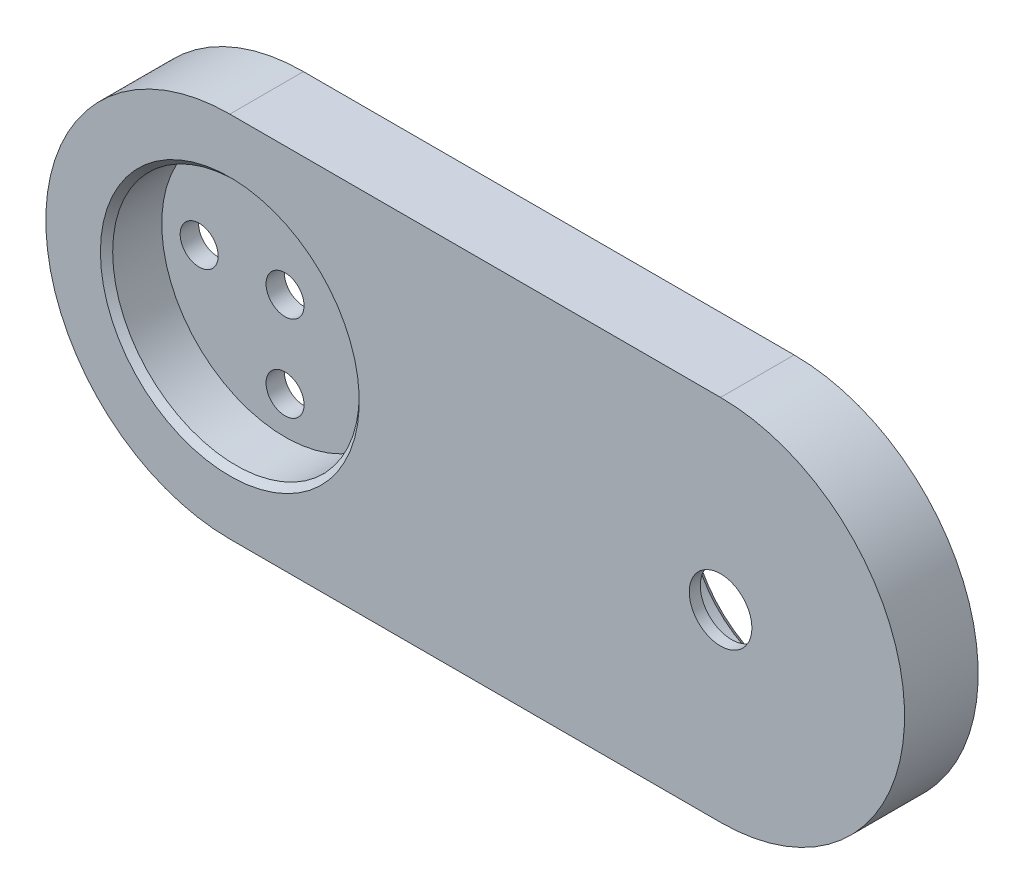
from build123d import *

# Parameters (mm, degrees)
BOSS_EXTRUDE1_DEPTH = 6
SKETCH8_R           = 10.05
CUT_EXTRUDE4_DEPTH  = 4.5
SKETCH9_R           = 7.975
CUT_EXTRUDE5_DEPTH  = 5.1
SKETCH10_R          = 2.55
CUT_EXTRUDE6_DEPTH  = 1.9
SKETCH11_R          = 1.55
CUT_EXTRUDE7_DEPTH  = 2.5
CHAMFER1_SIZE       = 0.5


with BuildPart() as part:
    # Sketch4 → Boss-Extrude1 (new body)
    with BuildSketch(Plane.XY):
        with BuildLine():
            Line((-20, 15), (20, 15))
            ThreePointArc((20, 15), (35, 0), (20, -15))
            Line((20, -15), (-20, -15))
            ThreePointArc((-20, -15), (-35, 0), (-20, 15))
        make_face()
    extrude(amount=BOSS_EXTRUDE1_DEPTH)

    # Sketch8 → Cut-Extrude4 (cut)
    with BuildSketch(Plane.XY.offset(6)):
        with Locations((-20, 0)):
            Circle(SKETCH8_R)
    extrude(amount=-CUT_EXTRUDE4_DEPTH, mode=Mode.SUBTRACT)

    # Sketch9 → Cut-Extrude5 (cut)
    with BuildSketch(Plane(origin=(0, 0, 0), x_dir=(-1, 0, 0), z_dir=(0, 0, -1))):
        with Locations((-20, 0)):
            Circle(SKETCH9_R)
    extrude(amount=-CUT_EXTRUDE5_DEPTH, mode=Mode.SUBTRACT)

    # Sketch10 → Cut-Extrude6 (cut, through all)
    with BuildSketch(Plane(origin=(0, 0, 5.1), x_dir=(-1, 0, 0), z_dir=(0, 0, -1))):
        with Locations((-20, 0)):
            Circle(SKETCH10_R)
    extrude(amount=-CUT_EXTRUDE6_DEPTH, mode=Mode.SUBTRACT)

    # Sketch11 → Cut-Extrude7 (cut, through all)
    with BuildSketch(Plane.XY.offset(1.5)):
        with Locations((-20, 0)):
            Circle(SKETCH11_R)
        with Locations((-13, 0)):
            Circle(SKETCH11_R)
        with Locations((-27, 0)):
            Circle(SKETCH11_R)
        with Locations((-20, 7)):
            Circle(SKETCH11_R)
        with Locations((-20, -7)):
            Circle(SKETCH11_R)
    extrude(amount=-CUT_EXTRUDE7_DEPTH, mode=Mode.SUBTRACT)

    # Chamfer1
    chamfer1_edges = [part.edges().sort_by_distance(p)[0] for p in [
        (-30.05, 0, 6),
        (27.975, 0, 0),
    ]]
    chamfer(chamfer1_edges, length=CHAMFER1_SIZE)


solid = part.part
